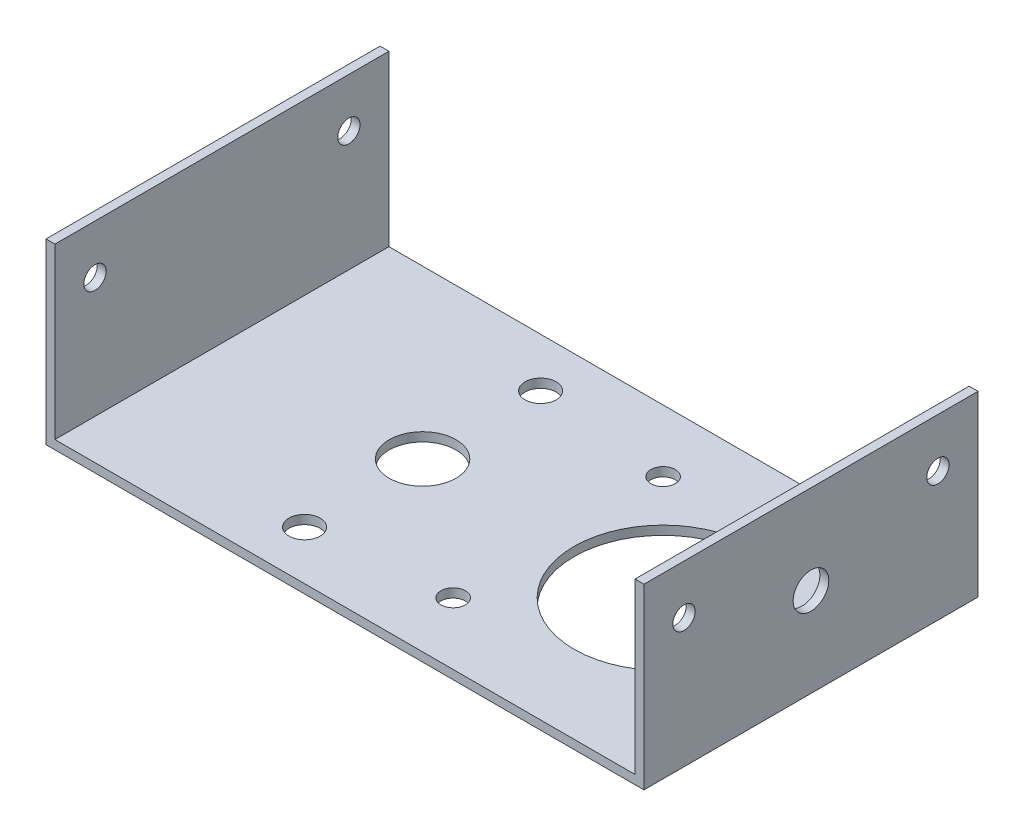
from build123d import *

# Parameters (mm, degrees)
ESBO_O1_W                = 62.4
ESBO_O1_H                = 75
RESSALTO_EXTRUS_O1_DEPTH = 2
ESBO_O2_W                = 75
ESBO_O2_H                = 40
RESSALTO_EXTRUS_O2_DEPTH = 2
ESBO_O3_R                = 2.5
CORTE_EXTRUS_O1_DEPTH    = 67.4
ESBO_O4_R                = 20
CORTE_EXTRUS_O2_DEPTH    = 5
ESBO_O5_R                = 2.75
CORTE_EXTRUS_O3_DEPTH    = 3
ESBO_O11_W               = 75
ESBO_O11_H               = 40
RESSALTO_EXTRUS_O3_DEPTH = 67.85
ESBO_O12_W               = 75
ESBO_O12_H               = 38
CORTE_EXTRUS_O4_DEPTH    = 67.85
ESBO_O13_R               = 2.5
CORTE_EXTRUS_O5_DEPTH    = 64.1
ESBO_O14_R               = 7.5
CORTE_EXTRUS_O6_DEPTH    = 10
CORTE_EXTRUS_O7_DEPTH    = 10
ESBO_O17_R               = 4
CORTE_EXTRUS_O8_DEPTH    = 10


with BuildPart() as part:
    # Esboço1 → Ressalto-extrusão1 (new body)
    with BuildSketch(Plane(origin=(0, 0, 0), x_dir=(1, 0, 0), z_dir=(0, 1, 0))):
        Rectangle(ESBO_O1_W, ESBO_O1_H)
    extrude(amount=RESSALTO_EXTRUS_O1_DEPTH)

    # Esboço2 → Ressalto-extrusão2 (add)
    with BuildSketch(Plane(origin=(31.2, 0, 0), x_dir=(0, 0, -1), z_dir=(1, 0, 0))):
        with Locations((0, 20)):
            Rectangle(ESBO_O2_W, ESBO_O2_H)
    ressalto_extrus_o2 = extrude(amount=RESSALTO_EXTRUS_O2_DEPTH)

    # Espelhar1: Ressalto-extrusão2 across plane
    add(ressalto_extrus_o2.mirror(Plane(origin=(0, 0, 0), x_dir=(0, 0, 1), z_dir=(1, 0, 0))))

    # Esboço3 → Corte-extrusão1 (cut, through all)
    with BuildSketch(Plane.ZY.offset(33.2)):
        with Locations((-28.5, 29)):
            Circle(ESBO_O3_R)
        with Locations((28.5, 29)):
            Circle(ESBO_O3_R)
    extrude(amount=-CORTE_EXTRUS_O1_DEPTH, mode=Mode.SUBTRACT)

    # Esboço4 → Corte-extrusão2 (cut)
    with BuildSketch(Plane(origin=(0, 2, 0), x_dir=(1, 0, 0), z_dir=(0, 1, 0))):
        Circle(ESBO_O4_R)
    extrude(amount=-CORTE_EXTRUS_O2_DEPTH, mode=Mode.SUBTRACT)

    # Esboço5 → Corte-extrusão3 (cut, through all)
    with BuildSketch(Plane(origin=(0, 2, 0), x_dir=(1, 0, 0), z_dir=(0, 1, 0))):
        with Locations((23.57, 23.57)):
            Circle(ESBO_O5_R)
        with Locations((23.57, -23.57)):
            Circle(ESBO_O5_R)
        with Locations((-23.57, -23.57)):
            Circle(ESBO_O5_R)
        with Locations((-23.57, 23.57)):
            Circle(ESBO_O5_R)
    extrude(amount=-CORTE_EXTRUS_O3_DEPTH, mode=Mode.SUBTRACT)

    # Esboço11 → Ressalto-extrusão3 (add)
    with BuildSketch(Plane.ZY.offset(33.2)):
        with Locations((0, 20)):
            Rectangle(ESBO_O11_W, ESBO_O11_H)
    extrude(amount=RESSALTO_EXTRUS_O3_DEPTH)

    # Esboço12 → Corte-extrusão4 (cut)
    with BuildSketch(Plane(origin=(-31.2, 0, 0), x_dir=(0, 0, -1), z_dir=(1, 0, 0))):
        with Locations((0, 21)):
            Rectangle(ESBO_O12_W, ESBO_O12_H)
    extrude(amount=-CORTE_EXTRUS_O4_DEPTH, mode=Mode.SUBTRACT)

    # Esboço13 → Corte-extrusão5 (cut)
    with BuildSketch(Plane(origin=(-99.05, 0, 0), x_dir=(0, 0, -1), z_dir=(1, 0, 0))):
        with Locations((28.5, 29)):
            Circle(ESBO_O13_R)
        with Locations((-28.5, 29)):
            Circle(ESBO_O13_R)
    extrude(amount=-CORTE_EXTRUS_O5_DEPTH, mode=Mode.SUBTRACT)

    # Esboço14 → Corte-extrusão6 (cut)
    with BuildSketch(Plane(origin=(0, 2, 0), x_dir=(1, 0, 0), z_dir=(0, 1, 0))):
        with Locations((-54, 0)):
            Circle(ESBO_O14_R)
    extrude(amount=-CORTE_EXTRUS_O6_DEPTH, mode=Mode.SUBTRACT)

    # Esboço16 → Corte-extrusão7 (cut)
    with BuildSketch(Plane(origin=(0, 2, 0), x_dir=(1, 0, 0), z_dir=(0, 1, 0))):
        with BuildLine():
            ThreePointArc((-57.5, 26.5), (-54, 23), (-50.5, 26.5))
            ThreePointArc((-50.5, 26.5), (-54, 30), (-57.5, 26.5))
        make_face()
        with BuildLine():
            ThreePointArc((-50.5, -26.5), (-54, -23), (-57.5, -26.5))
            ThreePointArc((-57.5, -26.5), (-54, -30), (-50.5, -26.5))
        make_face()
    extrude(amount=-CORTE_EXTRUS_O7_DEPTH, mode=Mode.SUBTRACT)

    # Esboço17 → Corte-extrusão8 (cut)
    with BuildSketch(Plane.ZY.offset(-31.2)):
        with Locations((0, 20)):
            Circle(ESBO_O17_R)
    extrude(amount=-CORTE_EXTRUS_O8_DEPTH, mode=Mode.SUBTRACT)


solid = part.part
